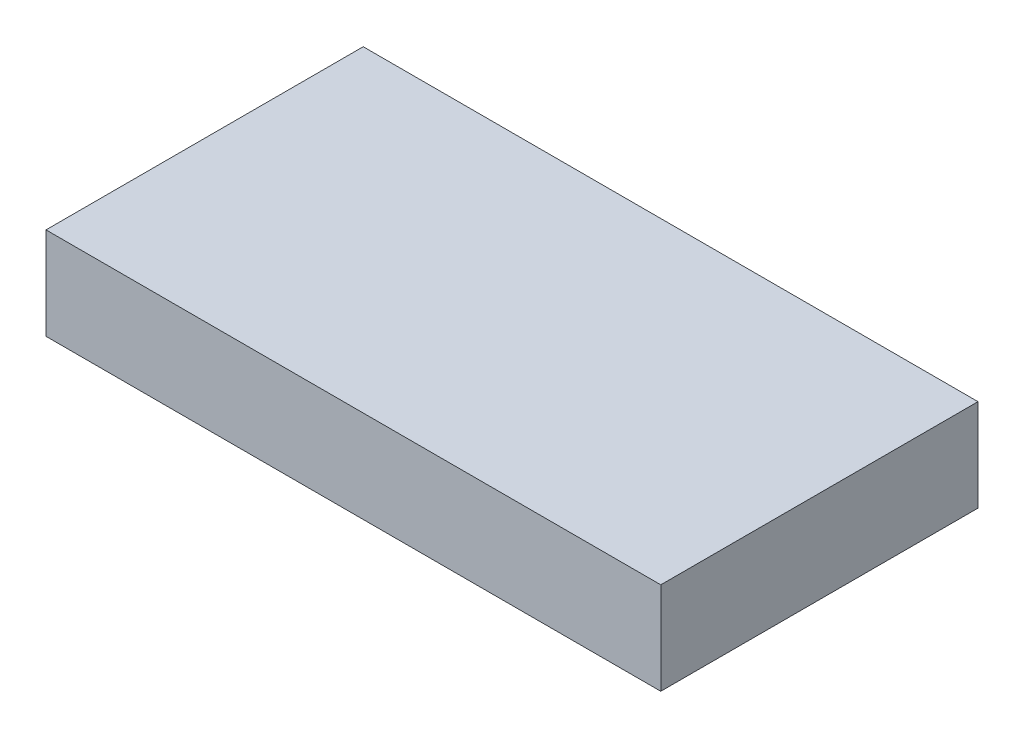
from build123d import *

# Parameters (mm, degrees)
CROQUIS3_W              = 50
CROQUIS3_H              = 25.8
SALIENTE_EXTRUIR3_DEPTH = 3.75


with BuildPart() as part:
    # Croquis3 → Saliente-Extruir3 (new body, symmetric)
    with BuildSketch(Plane(origin=(0, 0, 0), x_dir=(1, 0, 0), z_dir=(0, 1, 0))):
        Rectangle(CROQUIS3_W, CROQUIS3_H)
    extrude(amount=SALIENTE_EXTRUIR3_DEPTH, both=True)


solid = part.part
